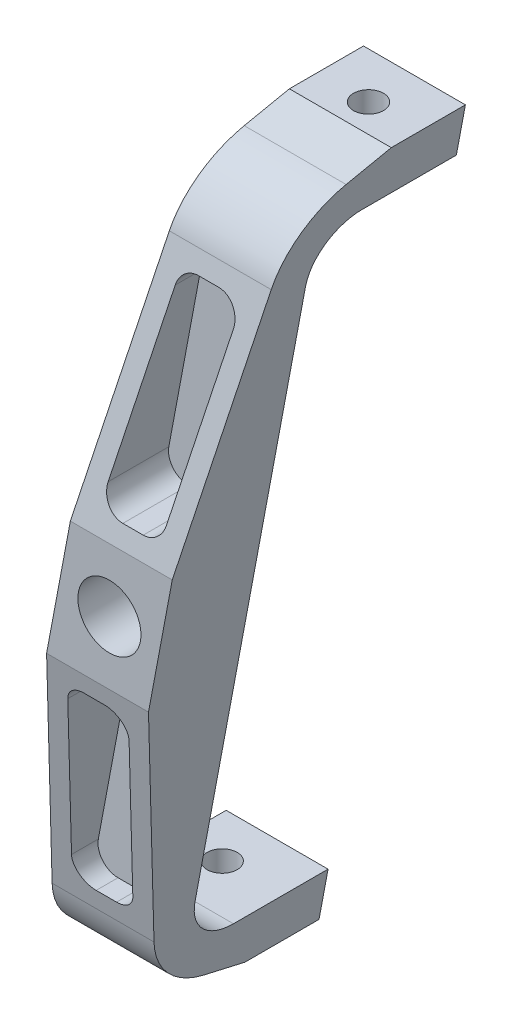
from build123d import *
from OCP.BRepFilletAPI import BRepFilletAPI_MakeChamfer

# Parameters (mm, degrees)
SKETCH1_R           = 10
BOSS_EXTRUDE1_DEPTH = 28.5
BOSS_EXTRUDE2_DEPTH = 45
CUT_EXTRUDE1_DEPTH  = 30
CIRPATTERN1_COUNT   = 2
CHAMFER1_SIZE       = 50
CHAMFER1_SIZE2      = 13.397459622
FILLET3_R           = 15
CHAMFER2_SIZE       = 90
CHAMFER2_SIZE2      = 13.607292824
CUT_EXTRUDE2_DEPTH  = 138.142132616
CUT_EXTRUDE4_DEPTH  = 22.15
FILLET6_R           = 6.35


with BuildPart() as part:
    # Sketch1 → Boss-Extrude1 (new body)
    with BuildSketch(Plane.XY):
        Polygon((-7.047570808, -123.427136592), (39.353608362, 123.427136592), (7.047570808, 123.427136592), (-39.353608362, -123.427136592), align=None)
        with Locations(Location((0, 0, 0), (0, 0, 180))):
            Circle(SKETCH1_R, mode=Mode.SUBTRACT)
    extrude(amount=BOSS_EXTRUDE1_DEPTH)

    # Sketch2 → Boss-Extrude2 (add)
    with BuildSketch(Plane(origin=(0, 0, 0), x_dir=(-1, 0, 0), z_dir=(0, 0, -1))):
        Polygon((-39.353608362, 123.427136592), (-36.488946708, 108.187136592), (-4.182909154, 108.187136592), (-7.047570808, 123.427136592), align=None)
        Polygon((36.488946708, -108.187136592), (4.182909154, -108.187136592), (7.047570808, -123.427136592), (39.353608362, -123.427136592), align=None)
    extrude(amount=BOSS_EXTRUDE2_DEPTH)

    # Sketch4 → Cut-Extrude1 (cut)
    with BuildSketch(Plane(origin=(0, 123.427136592, 0), x_dir=(1, 0, 0), z_dir=(0, 1, 0))):
        with BuildLine():
            ThreePointArc((18.438089585, 30.433032299), (19.83299354, 27.065436254), (23.200589585, 25.670532299))
            Line((23.200589585, 25.670532299), (23.200589585, 30.433032299))
            Line((23.200589585, 30.433032299), (18.438089585, 30.433032299))
        make_face()
        with BuildLine():
            Line((23.200589585, 30.433032299), (23.200589585, 25.670532299))
            ThreePointArc((23.200589585, 25.670532299), (26.56818563, 27.065436254), (27.963089585, 30.433032299))
            Line((27.963089585, 30.433032299), (23.200589585, 30.433032299))
        make_face()
        with BuildLine():
            Line((18.438089585, 30.433032299), (23.200589585, 30.433032299))
            Line((23.200589585, 30.433032299), (23.200589585, 35.195532299))
            ThreePointArc((23.200589585, 35.195532299), (19.83299354, 33.800628344), (18.438089585, 30.433032299))
        make_face()
        with BuildLine():
            Line((23.200589585, 35.195532299), (23.200589585, 30.433032299))
            Line((23.200589585, 30.433032299), (27.963089585, 30.433032299))
            ThreePointArc((27.963089585, 30.433032299), (26.56818563, 33.800628344), (23.200589585, 35.195532299))
        make_face()
    cut_extrude1 = extrude(amount=-CUT_EXTRUDE1_DEPTH, mode=Mode.SUBTRACT)

    # CirPattern1: Cut-Extrude1 ×2 about axis
    cirpattern1_axis = Axis((0, 0, 28.5), (0, 0, -1))
    for i in range(1, CIRPATTERN1_COUNT):
        add(cut_extrude1.rotate(cirpattern1_axis, i * 360 / CIRPATTERN1_COUNT), mode=Mode.SUBTRACT)

    # Chamfer1: one chamfer whose edges measure the first distance from different faces: ONE call of the kernel's chamfer builder (chamfer() names one face for all edges)
    chamfer1_edges_1 = [part.edges().sort_by_distance(p)[0] for p in [
        (-23.200589585, -123.427136592, 28.5),
    ]]
    chamfer1_side_1 = [part.faces().sort_by_distance(p)[0] for p in [
        (-23.200589585, -123.427136592, -7.563719055),
    ]]
    chamfer1_edges_2 = [part.edges().sort_by_distance(p)[0] for p in [
        (23.200589585, 123.427136592, 28.5),
    ]]
    chamfer1_side_2 = [part.faces().sort_by_distance(p)[0] for p in [
        (23.200589585, 123.427136592, -7.563719055),
    ]]
    chamfer1 = BRepFilletAPI_MakeChamfer(part.part.solid().wrapped)
    for e in chamfer1_edges_1:
        chamfer1.Add(CHAMFER1_SIZE, CHAMFER1_SIZE2, e.wrapped, chamfer1_side_1[0].wrapped)  # the first distance lies on this face
    for e in chamfer1_edges_2:
        chamfer1.Add(CHAMFER1_SIZE, CHAMFER1_SIZE2, e.wrapped, chamfer1_side_2[0].wrapped)  # the first distance lies on this face
    add(Compound.cast(chamfer1.Shape()), mode=Mode.REPLACE)

    # Fillet3
    fillet3_edges = [part.edges().sort_by_distance(p)[0] for p in [
        (20.335927931, 108.187136592, 0),
        (-20.335927931, -108.187136592, 0),
    ]]
    fillet(fillet3_edges, radius=FILLET3_R)

    # Chamfer2
    chamfer2_edges = [part.edges().sort_by_distance(p)[0] for p in [
        (-20.682270107, -110.02967697, 28.5),
        (20.682270107, 110.02967697, 28.5),
    ]]
    chamfer2_side = [part.faces().sort_by_distance(p)[0] for p in [
        (13.872325433, 0.428701757, 28.5),
    ]]
    chamfer(chamfer2_edges, length=CHAMFER2_SIZE, length2=CHAMFER2_SIZE2, reference=chamfer2_side[0])

    # Sketch10 → Cut-Extrude2 (cut, symmetric)
    with BuildSketch(Plane(origin=(0, 0, 0), x_dir=(0, 0, -1), z_dir=(1, 0, 0))):
        with BuildLine():
            Line((-28.5, 20.02967697), (-11.939027322, 98.847487856))
            ThreePointArc((-11.939027322, 98.847487856), (-4.989688501, 112.112334692), (7.875417438, 119.776440697))
            Line((7.875417438, 119.776440697), (-24.698068362, 128.387749722))
            Line((-24.698068362, 128.387749722), (-33.956814005, 23.522391457))
            Line((-33.956814005, 23.522391457), (-28.5, 20.02967697))
        make_face()
    cut_extrude2 = extrude(amount=CUT_EXTRUDE2_DEPTH, both=True, mode=Mode.SUBTRACT)

    # Mirror1: Cut-Extrude2 across plane
    add(cut_extrude2.mirror(Plane.ZX), mode=Mode.SUBTRACT)

    # Sketch11 → Cut-Extrude4 (cut)
    with BuildSketch(Plane.XY.offset(28.5)):
        Polygon((14.650397163, 26.37967697), (-4.73322537, 26.37967697), (7.694934571, 92.497487856), (27.078557104, 92.497487856), align=None)
        Polygon((-14.650397163, -26.37967697), (4.73322537, -26.37967697), (-7.694934571, -92.497487856), (-27.078557104, -92.497487856), align=None)
    extrude(amount=-CUT_EXTRUDE4_DEPTH, mode=Mode.SUBTRACT)

    # Fillet6
    fillet6_edges = [part.edges().sort_by_distance(p)[0] for p in [
        (14.650397163, 26.37967697, 16.757878094),
        (-4.73322537, 26.37967697, 16.757878094),
        (7.694934571, 92.497487856, 9.811635567),
        (27.078557104, 92.497487856, 9.811635567),
        (-27.078557104, -92.497487856, 9.811635567),
        (-7.694934571, -92.497487856, 9.811635567),
        (4.73322537, -26.37967697, 16.757878094),
        (-14.650397163, -26.37967697, 16.757878094),
    ]]
    fillet(fillet6_edges, radius=FILLET6_R)


solid = part.part
